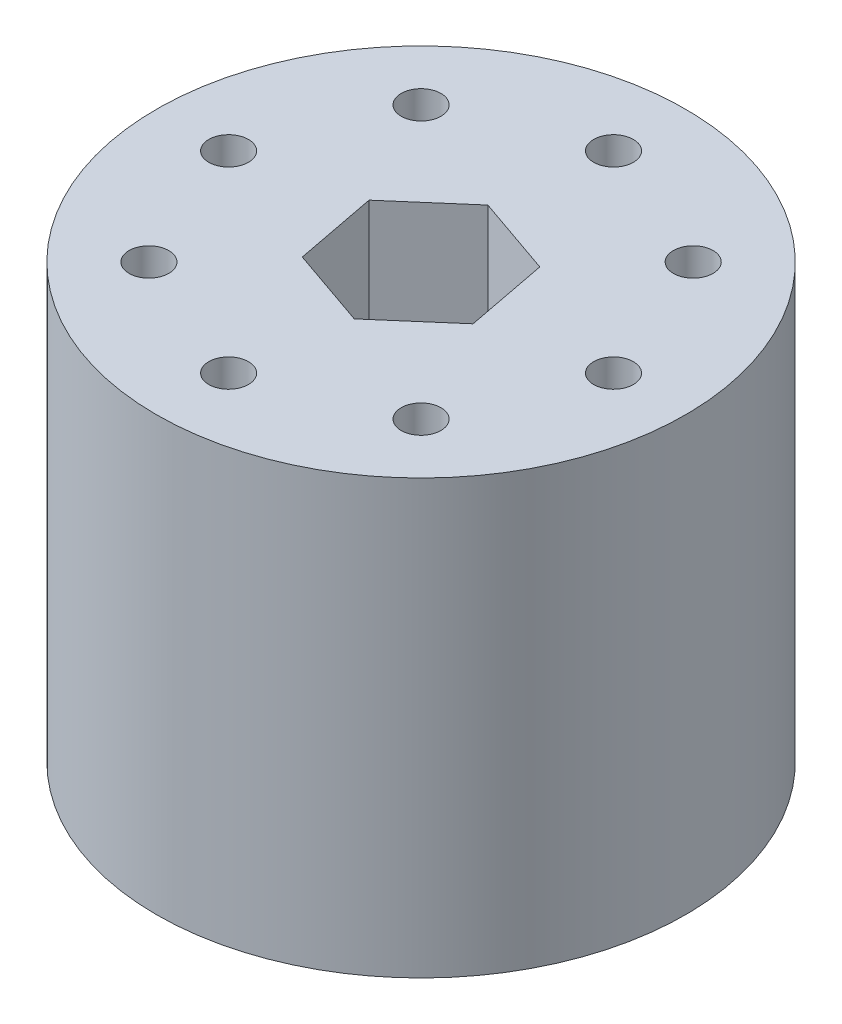
from build123d import *

# Parameters (mm, degrees)
SKETCH1_R           = 22
BOSS_EXTRUDE1_DEPTH = 36
SKETCH2_R           = 1.65
CUT_EXTRUDE1_DEPTH  = 36
CUT_EXTRUDE2_DEPTH  = 10
SKETCH4_R           = 2.3
CUT_EXTRUDE3_DEPTH  = 38
SKETCH5_R           = 5.59540043
CUT_EXTRUDE4_DEPTH  = 9


with BuildPart() as part:
    # Sketch1 → Boss-Extrude1 (new body)
    with BuildSketch(Plane(origin=(0, 0, 0), x_dir=(1, 0, 0), z_dir=(0, 1, 0))):
        Circle(SKETCH1_R)
    extrude(amount=BOSS_EXTRUDE1_DEPTH)

    # Sketch2 → Cut-Extrude1 (cut)
    with BuildSketch(Plane(origin=(0, 36, 0), x_dir=(1, 0, 0), z_dir=(0, 1, 0))):
        with Locations((-11.313708499, 11.313708499)):
            Circle(SKETCH2_R)
        with Locations((0, 16)):
            Circle(SKETCH2_R)
        with Locations((16, 0)):
            Circle(SKETCH2_R)
        with Locations((11.313708499, 11.313708499)):
            Circle(SKETCH2_R)
        with Locations((0, -16)):
            Circle(SKETCH2_R)
        with Locations((11.313708499, -11.313708499)):
            Circle(SKETCH2_R)
        with Locations((-16, 0)):
            Circle(SKETCH2_R)
        with Locations((-11.313708499, -11.313708499)):
            Circle(SKETCH2_R)
    extrude(amount=-CUT_EXTRUDE1_DEPTH, mode=Mode.SUBTRACT)

    # Sketch3 → Cut-Extrude2 (cut)
    with BuildSketch(Plane(origin=(0, 36, 0), x_dir=(1, 0, 0), z_dir=(0, 1, 0))):
        Polygon((1.321693068, -6.874091026), (6.613983991, -2.29242574), (5.292290922, 4.581665286), (-1.321693068, 6.874091026), (-6.613983991, 2.29242574), (-5.292290922, -4.581665286), align=None)
    extrude(amount=-CUT_EXTRUDE2_DEPTH, mode=Mode.SUBTRACT)

    # Sketch4 → Cut-Extrude3 (cut)
    with BuildSketch(Plane(origin=(0, 26, 0), x_dir=(1, 0, 0), z_dir=(0, 1, 0))):
        Circle(SKETCH4_R)
    extrude(amount=-CUT_EXTRUDE3_DEPTH, mode=Mode.SUBTRACT)

    # Sketch5 → Cut-Extrude4 (cut)
    with BuildSketch(Plane(origin=(0, 0, 0), x_dir=(-1, 0, 0), z_dir=(0, -1, 0))):
        Circle(SKETCH5_R)
    extrude(amount=-CUT_EXTRUDE4_DEPTH, mode=Mode.SUBTRACT)


solid = part.part
